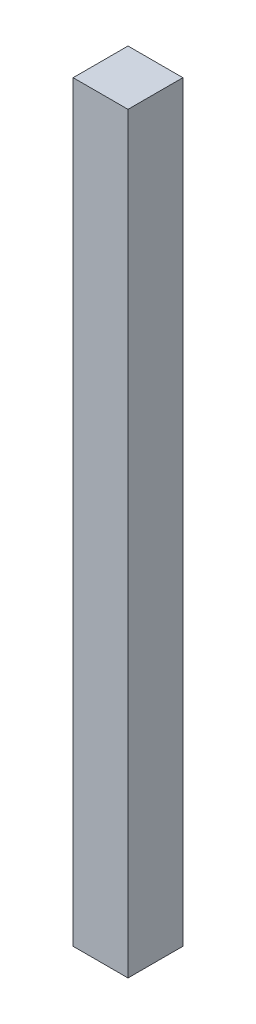
from build123d import *

# Parameters (mm, degrees)
SKETCH1_W           = 88.9
SKETCH1_H           = 88.9
BOSS_EXTRUDE1_DEPTH = 1219.2


with BuildPart() as part:
    # Sketch1 → Boss-Extrude1 (new body)
    with BuildSketch(Plane(origin=(0, 0, 0), x_dir=(1, 0, 0), z_dir=(0, 1, 0))):
        with Locations((-44.45, 44.45)):
            Rectangle(SKETCH1_W, SKETCH1_H)
    extrude(amount=BOSS_EXTRUDE1_DEPTH)


solid = part.part
